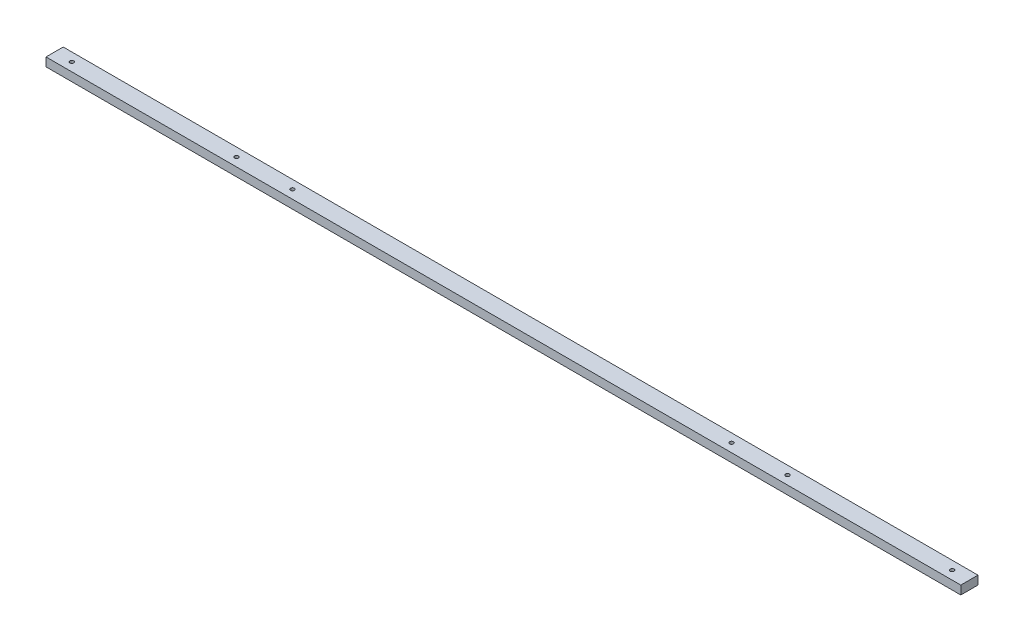
from build123d import *

# Parameters (mm, degrees)
SKETCH1_W           = 12.7
SKETCH1_H           = 6.35
BOSS_EXTRUDE1_DEPTH = 337.34375
SKETCH2_R           = 1.4224
CUT_EXTRUDE1_DEPTH  = 7.35


with BuildPart() as part:
    # Sketch1 → Boss-Extrude1 (new body, symmetric)
    with BuildSketch(Plane(origin=(0, 0, 0), x_dir=(0, 0, -1), z_dir=(1, 0, 0))):
        Rectangle(SKETCH1_W, SKETCH1_H)
    extrude(amount=BOSS_EXTRUDE1_DEPTH, both=True)

    # Sketch2 → Cut-Extrude1 (cut, through all)
    with BuildSketch(Plane(origin=(0, 3.175, 0), x_dir=(1, 0, 0), z_dir=(0, 1, 0))):
        with Locations(Location((161.925, 0, 0), (0, 0, 270))):  # turned: the seam where the file's is
            Circle(SKETCH2_R)
        with Locations(Location((203.2, 0, 0), (0, 0, 270))):  # turned: the seam where the file's is
            Circle(SKETCH2_R)
        with Locations(Location((-203.2, 0, 0), (0, 0, 90))):  # turned: the seam where the file's is
            Circle(SKETCH2_R)
        with Locations(Location((-161.925, 0, 0), (0, 0, 90))):  # turned: the seam where the file's is
            Circle(SKETCH2_R)
        with Locations(Location((324.64375, 0, 0), (0, 0, 270))):  # turned: the seam where the file's is
            Circle(SKETCH2_R)
        with Locations(Location((-324.64375, 0, 0), (0, 0, 90))):  # turned: the seam where the file's is
            Circle(SKETCH2_R)
    extrude(amount=-CUT_EXTRUDE1_DEPTH, mode=Mode.SUBTRACT)


solid = part.part
